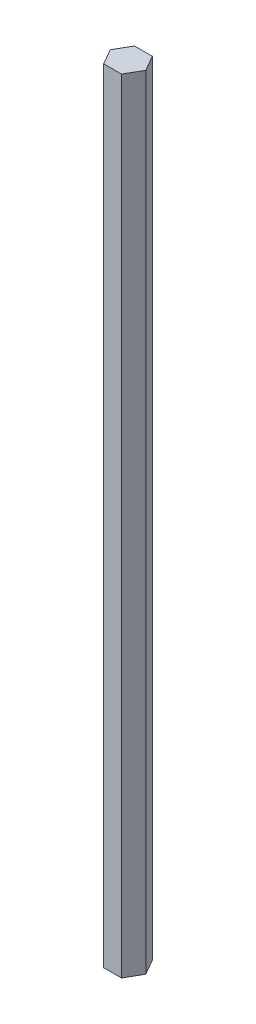
from build123d import *

# Parameters (mm, degrees)
BOSS_EXTRUDE1_DEPTH = 352


with BuildPart() as part:
    # Sketch1 → Boss-Extrude1 (new body)
    with BuildSketch(Plane(origin=(0, 0, 0), x_dir=(1, 0, 0), z_dir=(0, 1, 0))):
        Polygon((7.977059052, 1.579344013), (3.977059052, 8.507547244), (-4.022940948, 8.507547244), (-8.022940948, 1.579344013), (-4.022940948, -5.348859217), (3.977059052, -5.348859217), align=None)
    extrude(amount=BOSS_EXTRUDE1_DEPTH)


solid = part.part
